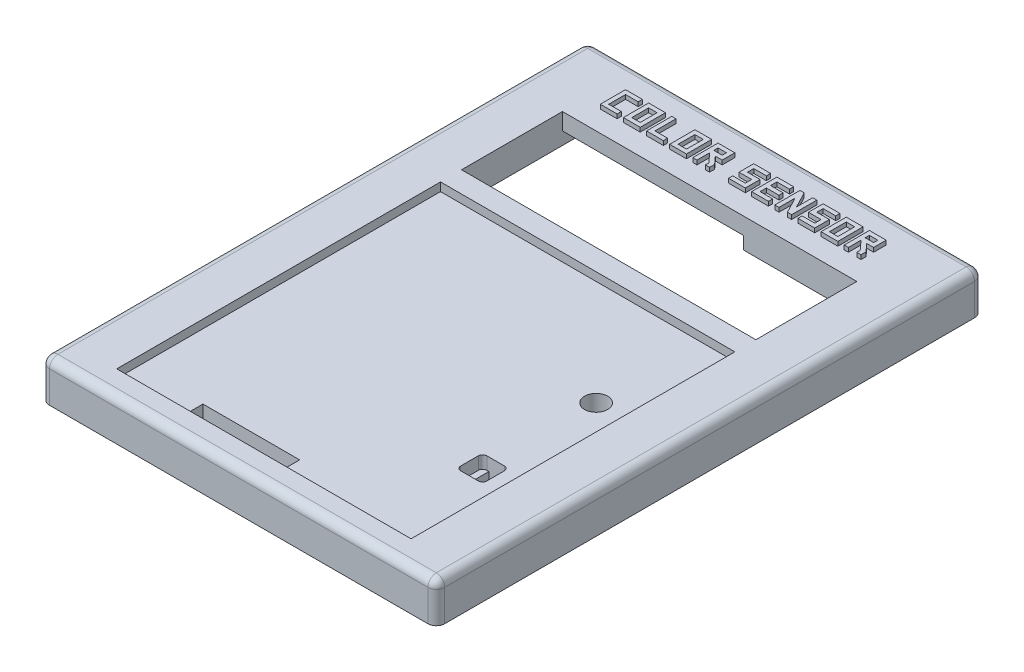
from build123d import *

# Parameters (mm, degrees)
SKETCH1_W                = 94
SKETCH1_H                = 130
BOSS_EXTRUDE1_DEPTH      = 9.5
SKETCH2_W                = 90.5
SKETCH2_H                = 126.5
CUT_EXTRUDE1_DEPTH       = 2.5
SKETCH3_W                = 70
SKETCH3_H                = 24
CUT_EXTRUDE2_DEPTH       = 8
SKETCH4_W                = 70
SKETCH4_H                = 77
CUT_EXTRUDE3_DEPTH       = 2
SKETCH5_W                = 23
SKETCH5_H                = 3.5
CUT_EXTRUDE4_DEPTH       = 8.5
SKETCH6_W                = 6
SKETCH6_H                = 18
CUT_EXTRUDE5_DEPTH       = 3.5
SKETCH7_W                = 43
SKETCH7_H                = 7.5
CUT_EXTRUDE6_DEPTH       = 3
FILLET1_R                = 2
SKETCH9_R                = 2.75
CUT_EXTRUDE7_DEPTH       = 5
SKETCH12_W               = 6.2
SKETCH12_H               = 6.2
CUT_EXTRUDE9_DEPTH       = 3
SKETCH13_W               = 3.2
SKETCH13_H               = 6.2
CUT_EXTRUDE10_DEPTH      = 6
CUT_EXTRUDE10_DEPTH_BACK = 5.5
FILLET2_R                = 1
SKETCH14_R               = 4
BOSS_EXTRUDE2_DEPTH      = 3
SKETCH15_R               = 2.8
CUT_EXTRUDE11_DEPTH      = 1.5
SKETCH16_R               = 2.4
CUT_EXTRUDE12_DEPTH      = 1.5
SKETCH18_W               = 4
SKETCH18_H               = 6
SKETCH18_W_2             = 2
SKETCH18_H_2             = 4
SKETCH18_H_3             = 1
BOSS_EXTRUDE3_DEPTH      = 1


with BuildPart() as part:
    # Sketch1 → Boss-Extrude1 (new body)
    with BuildSketch(Plane(origin=(0, 7, 0), x_dir=(1, 0, 0), z_dir=(0, 1, 0))):
        with Locations((47, 65)):
            Rectangle(SKETCH1_W, SKETCH1_H)
    extrude(amount=-BOSS_EXTRUDE1_DEPTH)

    # Sketch2 → Cut-Extrude1 (cut)
    with BuildSketch(Plane.XZ.offset(2.5)):
        with Locations((47, -65)):
            Rectangle(SKETCH2_W, SKETCH2_H)
    extrude(amount=-CUT_EXTRUDE1_DEPTH, mode=Mode.SUBTRACT)

    # Sketch3 → Cut-Extrude2 (cut, through all)
    with BuildSketch(Plane.XZ):
        with Locations((47, -100)):
            Rectangle(SKETCH3_W, SKETCH3_H)
    extrude(amount=-CUT_EXTRUDE2_DEPTH, mode=Mode.SUBTRACT)

    # Sketch4 → Cut-Extrude3 (cut)
    with BuildSketch(Plane(origin=(0, 7, 0), x_dir=(-1, 0, 0), z_dir=(0, 1, 0))):
        with Locations((-47, -44.5)):
            Rectangle(SKETCH4_W, SKETCH4_H)
    extrude(amount=-CUT_EXTRUDE3_DEPTH, mode=Mode.SUBTRACT)

    # Sketch5 → Cut-Extrude4 (cut, through all)
    with BuildSketch(Plane(origin=(0, 5, 0), x_dir=(-1, 0, 0), z_dir=(0, 1, 0))):
        with Locations((-39, -9.25)):
            Rectangle(SKETCH5_W, SKETCH5_H)
    extrude(amount=-CUT_EXTRUDE4_DEPTH, mode=Mode.SUBTRACT)

    # Sketch6 → Cut-Extrude5 (cut)
    with BuildSketch(Plane.XZ):
        with Locations((85, -100)):
            Rectangle(SKETCH6_W, SKETCH6_H)
    extrude(amount=-CUT_EXTRUDE5_DEPTH, mode=Mode.SUBTRACT)

    # Sketch7 → Cut-Extrude6 (cut)
    with BuildSketch(Plane.XZ):
        with Locations((33.5, -115.75)):
            Rectangle(SKETCH7_W, SKETCH7_H)
    extrude(amount=-CUT_EXTRUDE6_DEPTH, mode=Mode.SUBTRACT)

    # Fillet1
    fillet1_edges = [part.edges().sort_by_distance(p)[0] for p in [
        (94, 7, -65),
        (47, 7, 0),
        (0, 7, -65),
        (47, 7, -130),
        (94, 2.25, -130),
        (94, 2.25, 0),
        (0, 2.25, 0),
        (0, 2.25, -130),
    ]]
    fillet(fillet1_edges, radius=FILLET1_R)

    # Sketch9 → Cut-Extrude7 (cut)
    with BuildSketch(Plane(origin=(0, 5, 0), x_dir=(1, 0, 0), z_dir=(0, 1, 0))):
        with Locations((74, 58)):
            Circle(SKETCH9_R)
    extrude(amount=-CUT_EXTRUDE7_DEPTH, mode=Mode.SUBTRACT)

    # Sketch12 → Cut-Extrude9 (cut)
    with BuildSketch(Plane(origin=(0, 5, 0), x_dir=(1, 0, 0), z_dir=(0, 1, 0))):
        with Locations((74, 31)):
            Rectangle(SKETCH12_W, SKETCH12_H)
    extrude(amount=-CUT_EXTRUDE9_DEPTH, mode=Mode.SUBTRACT)

    # Sketch13 → Cut-Extrude10 (cut, two sides)
    with BuildSketch(Plane(origin=(0, 2, 0), x_dir=(1, 0, 0), z_dir=(0, 1, 0))) as cut_extrude10_sk:
        with Locations((74, 31)):
            Rectangle(SKETCH13_W, SKETCH13_H)
    extrude(amount=CUT_EXTRUDE10_DEPTH, mode=Mode.SUBTRACT)
    extrude(cut_extrude10_sk.sketch, amount=-CUT_EXTRUDE10_DEPTH_BACK, mode=Mode.SUBTRACT)

    # Fillet2
    fillet2_edges = [part.edges().sort_by_distance(p)[0] for p in [
        (77.1, 3.5, -34.1),
        (77.1, 3.5, -27.9),
        (70.9, 3.5, -27.9),
        (70.9, 3.5, -34.1),
    ]]
    fillet(fillet2_edges, radius=FILLET2_R)

    # Sketch14 → Boss-Extrude2 (add)
    with BuildSketch(Plane.XZ):
        with Locations((74, -58)):
            Circle(SKETCH14_R)
    extrude(amount=BOSS_EXTRUDE2_DEPTH)

    # Sketch15 → Cut-Extrude11 (cut)
    with BuildSketch(Plane(origin=(0, 0, 0), x_dir=(1, 0, 0), z_dir=(0, 1, 0))):
        with Locations((74, 58)):
            Circle(SKETCH15_R)
    extrude(amount=-CUT_EXTRUDE11_DEPTH, mode=Mode.SUBTRACT)

    # Sketch16 → Cut-Extrude12 (cut)
    with BuildSketch(Plane(origin=(0, -1.5, 0), x_dir=(1, 0, 0), z_dir=(0, 1, 0))):
        with Locations((74, 58)):
            Circle(SKETCH16_R)
    extrude(amount=-CUT_EXTRUDE12_DEPTH, mode=Mode.SUBTRACT)

    # Sketch18 → Boss-Extrude3 (add)
    with BuildSketch(Plane(origin=(0, 7, 0), x_dir=(1, 0, 0), z_dir=(0, 1, 0))):
        Polygon((17, 122), (17, 118), (19, 118), (19.993343468, 118), (19.993343468, 117), (15.993343468, 117), (15.993343468, 123), (19.993343468, 123), (19.993343468, 122), (19, 122), align=None)
        Polygon((66.993343468, 122), (63.993343468, 122), (63.993343468, 120.5), (66.993343468, 120.5), (66.993343468, 117), (62.993343468, 117), (62.993343468, 118), (65.993343468, 118), (65.993343468, 119.5), (62.993343468, 119.5), (62.993343468, 123), (66.993343468, 123), align=None)
        with Locations((23.493343468, 120)):
            Rectangle(SKETCH18_W, SKETCH18_H)
        with Locations((23.493343468, 120)):
            Rectangle(SKETCH18_W_2, SKETCH18_H_2, mode=Mode.SUBTRACT)
        Polygon((27.993343468, 122), (27.993343468, 118), (29.109404955, 118), (30.993343468, 118), (30.993343468, 117), (26.993343468, 117), (26.993343468, 123), (27.993343468, 123), align=None)
        with Locations((34.493343468, 120)):
            Rectangle(SKETCH18_W, SKETCH18_H)
        with Locations((34.493343468, 120)):
            Rectangle(SKETCH18_W_2, SKETCH18_H_2, mode=Mode.SUBTRACT)
        Polygon((49.493343468, 122), (50.493343468, 122), (50.493343468, 123), (46.493343468, 123), (46.493343468, 119.5), (47.493343468, 119.5), (49.493343468, 119.5), (49.493343468, 118), (47.956084084, 118), (46.493343468, 118), (46.493343468, 117), (50.493343468, 117), (50.493343468, 120.5), (49.493343468, 120.5), (47.493343468, 120.5), (47.493343468, 122), align=None)
        Polygon((37.993343468, 123), (41.993343468, 123), (41.993343468, 120), (40.353343468, 120), (41.993343468, 118.2), (41.993343468, 117), (40.993343468, 117), (40.993343468, 117.812757926), (39.000522912, 120), (38.993343468, 120), (38.993343468, 118.442496016), (38.993343468, 117), (37.993343468, 117), align=None)
        with Locations((39.993343468, 121.5)):
            Rectangle(SKETCH18_W_2, SKETCH18_H_3, mode=Mode.SUBTRACT)
        Polygon((55.993343468, 122), (52.993343468, 122), (52.993343468, 120.5), (55.993343468, 120.5), (55.993343468, 119.5), (52.993343468, 119.5), (52.993343468, 118), (55.993343468, 118), (55.993343468, 117), (51.993343468, 117), (51.993343468, 123), (55.993343468, 123), align=None)
        Polygon((58.493343468, 123), (60.493343468, 119.163331999), (60.493343468, 123), (61.493343468, 123), (61.493343468, 117), (60.493343468, 117), (58.493343468, 120.836668001), (58.493343468, 117), (57.493343468, 117), (57.493343468, 123), align=None)
        with Locations((70.493343468, 120)):
            Rectangle(SKETCH18_W, SKETCH18_H)
        with Locations((70.493343468, 120)):
            Rectangle(SKETCH18_W_2, SKETCH18_H_2, mode=Mode.SUBTRACT)
        Polygon((74.993343468, 117), (74.993343468, 120), (75.000522912, 120), (76.993343468, 117.812757926), (76.993343468, 117), (77.993343468, 117), (77.993343468, 118.2), (76.353343468, 120), (77.993343468, 120), (77.993343468, 123), (73.993343468, 123), (73.993343468, 117), align=None)
        with Locations((75.993343468, 121.5)):
            Rectangle(SKETCH18_W_2, SKETCH18_H_3, mode=Mode.SUBTRACT)
    extrude(amount=BOSS_EXTRUDE3_DEPTH)


solid = part.part
